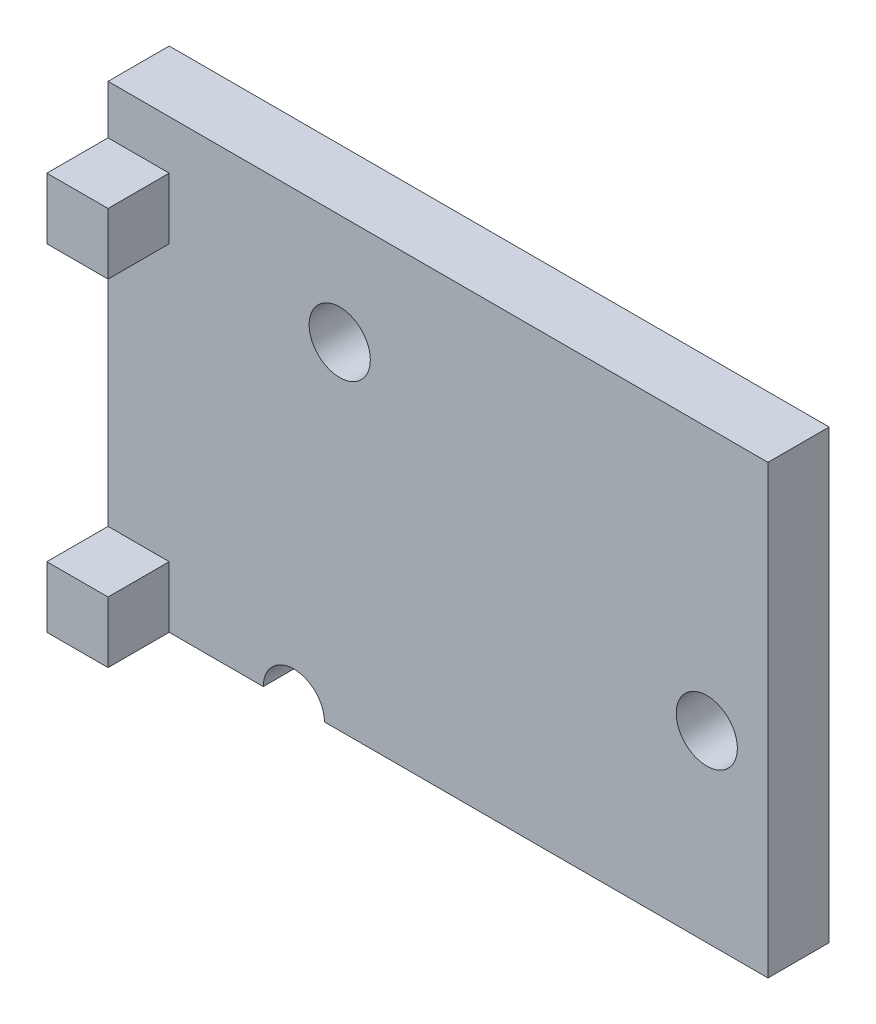
from build123d import *

# Parameters (mm, degrees)
SKETCH1_R            = 0.5
FRONT_FACE_EXT_DEPTH = 1
SKETCH2_W            = 1
SKETCH2_H            = 6.5
BOSS_EXTRUDE1_DEPTH  = 1.7874
SKETCH3_W            = 1
SKETCH3_H            = 1
BOSS_EXTRUDE2_DEPTH  = 1
SKETCH4_W            = 10.7874
SKETCH4_H            = 1
BOSS_EXTRUDE3_DEPTH  = 0.8


with BuildPart() as part:
    # Sketch1 → Front Face Ext (new body)
    with BuildSketch(Plane.XY):
        with BuildLine():
            Line((-3.75, -3.25), (-4.5, -3.25))
            Line((-4.5, -3.25), (-4.5, 3.25))
            Line((-4.5, 3.25), (4.5, 3.25))
            Line((4.5, 3.25), (4.5, -3.25))
            Line((4.5, -3.25), (-2.75, -3.25))
            ThreePointArc((-2.75, -3.25), (-3.25, -2.75), (-3.75, -3.25))
        make_face()
        with Locations((-2.5, 2.25)):
            Circle(SKETCH1_R, mode=Mode.SUBTRACT)
        with Locations((3.5, -0.25)):
            Circle(SKETCH1_R, mode=Mode.SUBTRACT)
    extrude(amount=FRONT_FACE_EXT_DEPTH)

    # Sketch2 → Boss-Extrude1 (add)
    with BuildSketch(Plane.ZY.offset(4.5)):
        with Locations((0.5, 0)):
            Rectangle(SKETCH2_W, SKETCH2_H)
    extrude(amount=BOSS_EXTRUDE1_DEPTH)

    # Sketch3 → Boss-Extrude2 (add)
    with BuildSketch(Plane.XY.offset(1)):
        with Locations((-5.7874, 2.75)):
            Rectangle(SKETCH3_W, SKETCH3_H)
        with Locations((-5.7874, -2.75)):
            Rectangle(SKETCH3_W, SKETCH3_H)
    extrude(amount=BOSS_EXTRUDE2_DEPTH)

    # Sketch4 → Boss-Extrude3 (add)
    with BuildSketch(Plane(origin=(0, 3.25, 0), x_dir=(1, 0, 0), z_dir=(0, 1, 0))):
        with Locations((-0.8937, -0.5)):
            Rectangle(SKETCH4_W, SKETCH4_H)
    extrude(amount=BOSS_EXTRUDE3_DEPTH)


solid = part.part
